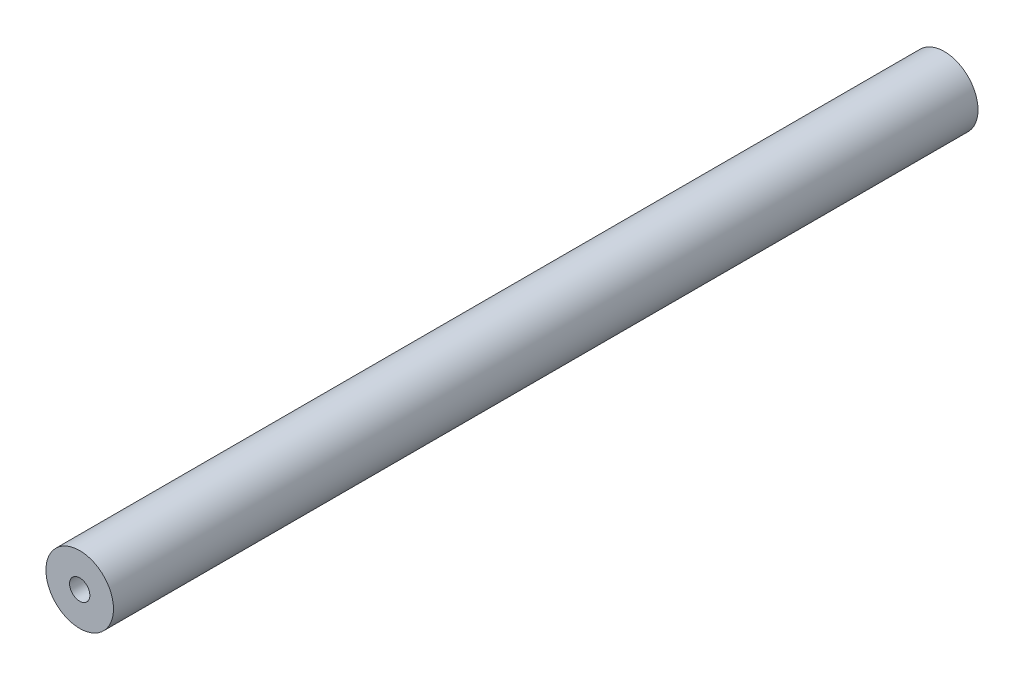
from build123d import *

# Parameters (mm, degrees)
SKETCH1_R           = 31.75
SKETCH1_R_2         = 9.525
BOSS_EXTRUDE1_DEPTH = 812.8


with BuildPart() as part:
    # Sketch1 → Boss-Extrude1 (new body)
    with BuildSketch(Plane.XY):
        Circle(SKETCH1_R)
        Circle(SKETCH1_R_2, mode=Mode.SUBTRACT)
    extrude(amount=BOSS_EXTRUDE1_DEPTH)


solid = part.part
